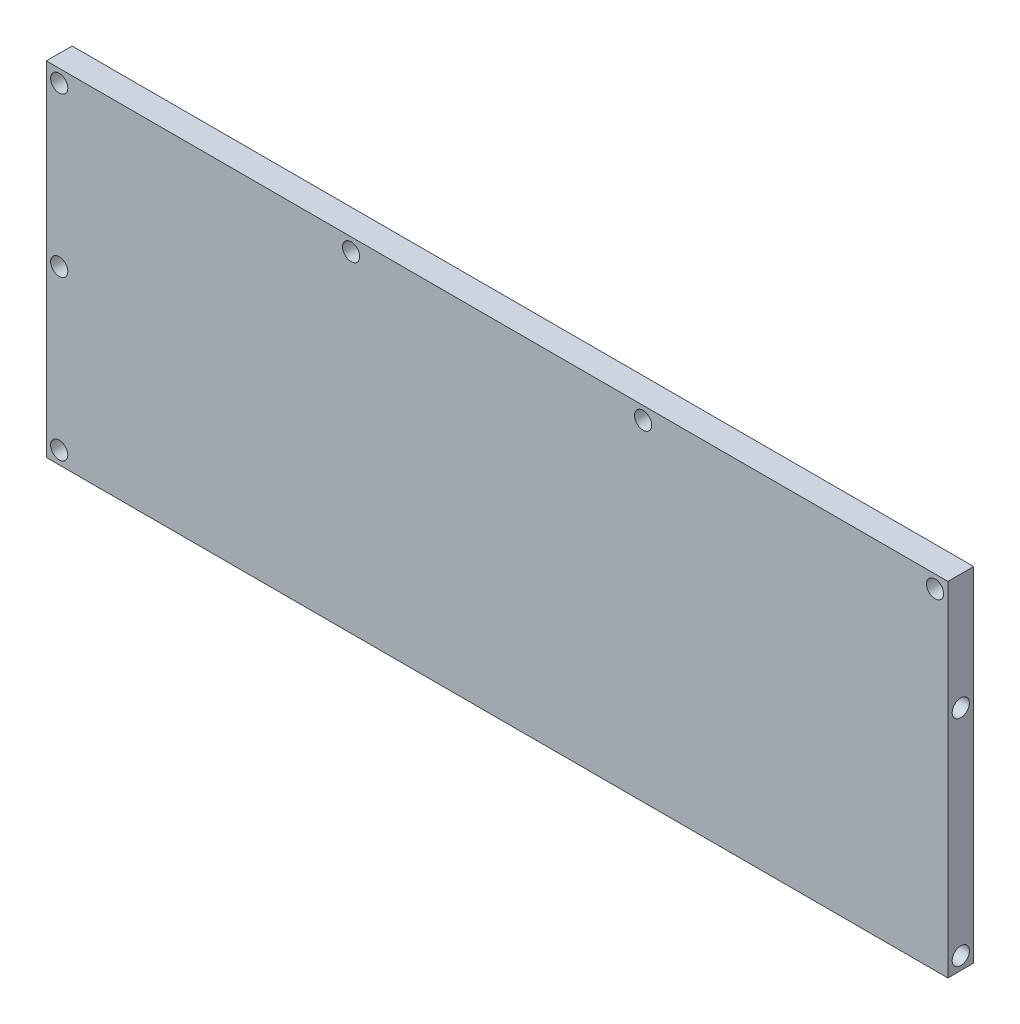
from build123d import *

# Parameters (mm, degrees)
SKETCH_1_W          = 210
SKETCH_1_H          = 80
EXTRUDE_1_DEPTH     = 6
SKETCH_2_R          = 2
CUT_EXTRUDE_1_DEPTH = 6
SKETCH_3_R          = 2
CUT_EXTRUDE_2_DEPTH = 20


with BuildPart() as part:
    # 草图1 → 凸台-拉伸1 (new body)
    with BuildSketch(Plane.XY):
        Rectangle(SKETCH_1_W, SKETCH_1_H)
    extrude(amount=EXTRUDE_1_DEPTH)

    # 草图2 → 切除-拉伸1 (cut)
    with BuildSketch(Plane.XY.offset(6)):
        with Locations((-102, 0)):
            Circle(SKETCH_2_R)
        with Locations((-102, 37)):
            Circle(SKETCH_2_R)
        with Locations((-102, -37)):
            Circle(SKETCH_2_R)
        with Locations((-34, 37)):
            Circle(SKETCH_2_R)
        with Locations((34, 37)):
            Circle(SKETCH_2_R)
        with Locations((102, 37)):
            Circle(SKETCH_2_R)
    extrude(amount=-CUT_EXTRUDE_1_DEPTH, mode=Mode.SUBTRACT)

    # 草图3 → 切除-拉伸2 (cut)
    with BuildSketch(Plane(origin=(105, 0, 0), x_dir=(0, 0, -1), z_dir=(1, 0, 0))):
        with Locations((-3, -37)):
            Circle(SKETCH_3_R)
        with Locations((-3, 13)):
            Circle(SKETCH_3_R)
    extrude(amount=-CUT_EXTRUDE_2_DEPTH, mode=Mode.SUBTRACT)


solid = part.part
